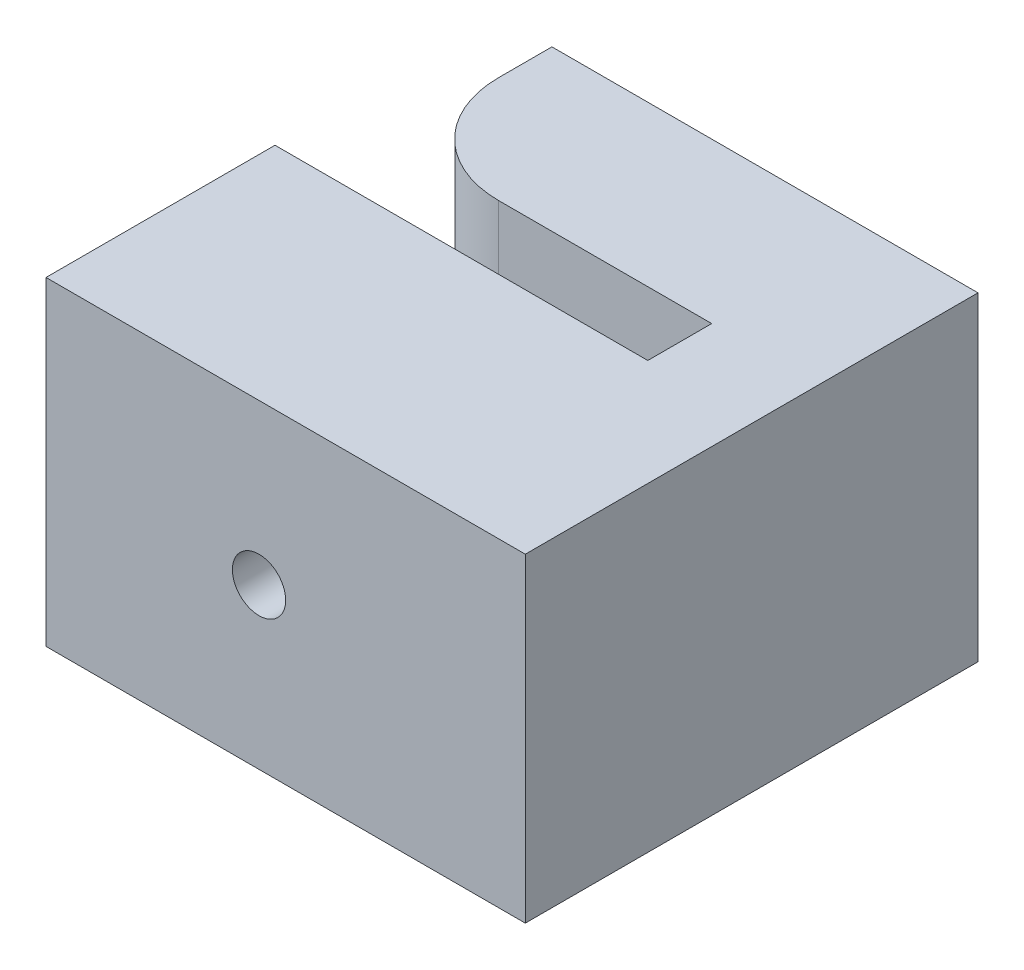
from build123d import *

# Parameters (mm, degrees)
BOSS_EXTRU_1_DEPTH      = 3
ESQUISSE3_R             = 0.5
ENL_V_MAT_EXTRU_1_DEPTH = 9.5
CONG_1_R                = 2


with BuildPart() as part:
    # Esquisse2 → Boss.-Extru.1 (new body, symmetric)
    with BuildSketch(Plane(origin=(0, 0, 0), x_dir=(1, 0, 0), z_dir=(0, 1, 0))):
        Polygon((-4, 1.25), (-4, 4.25), (4, 4.25), (4, -4.25), (-4, -4.25), (-5, -4.25), (-5, 0.05), (-4, 0.05), (2, 0.05), (2, 1.25), align=None)
    extrude(amount=BOSS_EXTRU_1_DEPTH, both=True)

    # Esquisse3 → Enlèv. mat.-Extru.1 (cut, through all)
    with BuildSketch(Plane(origin=(0, 0, -4.25), x_dir=(-1, 0, 0), z_dir=(0, 0, -1))):
        with Locations((1, 0)):
            Circle(ESQUISSE3_R)
    extrude(amount=-ENL_V_MAT_EXTRU_1_DEPTH, mode=Mode.SUBTRACT)

    # Congé1
    cong_1_edges = [part.edges().sort_by_distance(p)[0] for p in [
        (-4, 0, -1.25),
    ]]
    fillet(cong_1_edges, radius=CONG_1_R)


solid = part.part
